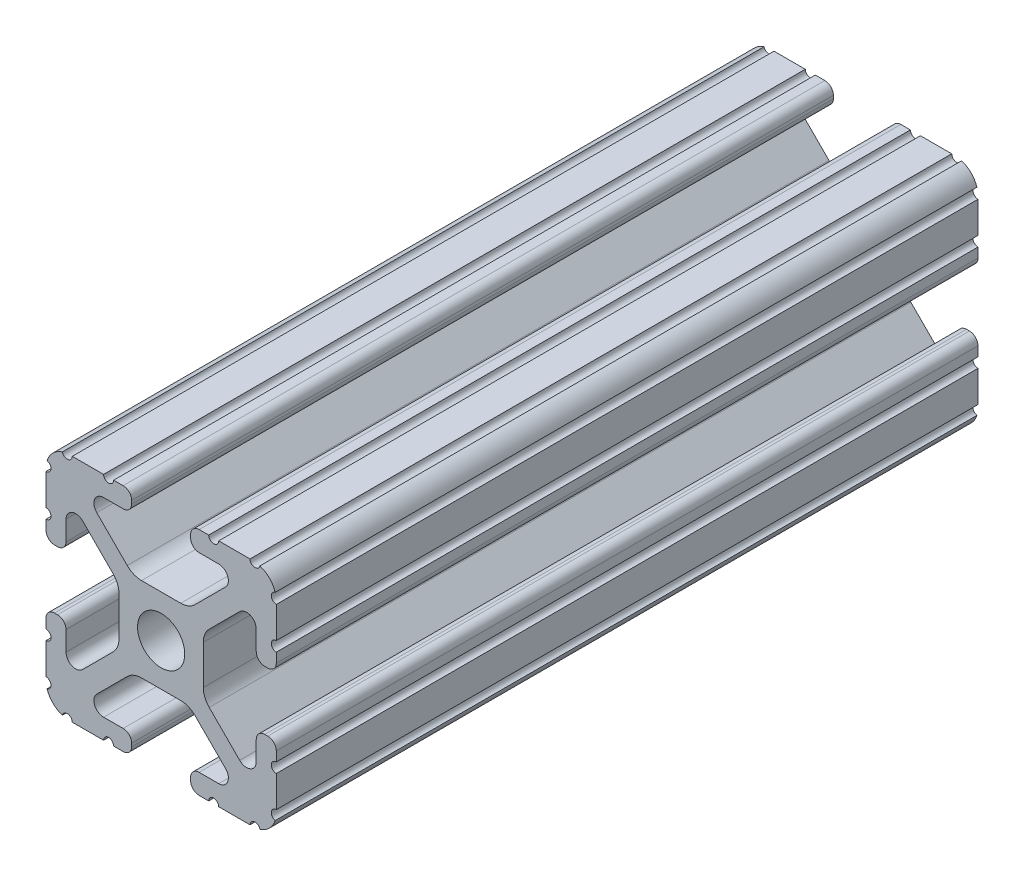
from build123d import *

# Parameters (mm, degrees)
BOSS_EXTRUDE1_DEPTH     = 38.7
SKETCH5_R               = 0.55245
CUT_EXTRUDE1_DEPTH      = 39.7
CUT_EXTRUDE1_DEPTH_BACK = 39.7


with BuildPart() as part:
    # Sketch4 → Boss-Extrude1 (new body, symmetric)
    with BuildSketch(Plane.XY):
        with BuildLine():
            Line((4.190365, -12.7), (10.11729625, -12.7))
            ThreePointArc((10.11729625, -12.7), (11.943543585, -11.943543585), (12.7, -10.11729625))
            Line((12.7, -10.11729625), (12.7, -4.190365))
            ThreePointArc((12.7, -4.190365), (12.42492494, -3.52627506), (11.760835, -3.2512))
            Line((11.760835, -3.2512), (11.429365, -3.2512))
            ThreePointArc((11.429365, -3.2512), (10.76527506, -3.52627506), (10.4902, -4.190365))
            Line((10.4902, -4.190365), (10.4902, -6.348478019))
            ThreePointArc((10.4902, -6.348478019), (9.830707141, -7.335478831), (8.666460301, -7.103895736))
            Line((8.666460301, -7.103895736), (5.299899128, -3.737334563))
            ThreePointArc((5.299899128, -3.737334563), (4.817571085, -3.015479634), (4.6482, -2.16399369))
            Line((4.6482, -2.16399369), (4.6482, 0))
            Line((4.6482, 0), (2.6035, 0))
            ThreePointArc((2.6035, 0), (1.840952505, -1.840952505), (0, -2.6035))
            Line((0, -2.6035), (0, -4.6482))
            Line((0, -4.6482), (2.16399369, -4.6482))
            ThreePointArc((2.16399369, -4.6482), (3.015479634, -4.817571085), (3.737334563, -5.299899128))
            Line((3.737334563, -5.299899128), (7.103895736, -8.666460301))
            ThreePointArc((7.103895736, -8.666460301), (7.335478831, -9.830707141), (6.348478019, -10.4902))
            Line((6.348478019, -10.4902), (4.190365, -10.4902))
            ThreePointArc((4.190365, -10.4902), (3.52627506, -10.76527506), (3.2512, -11.429365))
            Line((3.2512, -11.429365), (3.2512, -11.760835))
            ThreePointArc((3.2512, -11.760835), (3.52627506, -12.42492494), (4.190365, -12.7))
        make_face()
    extrude(amount=BOSS_EXTRUDE1_DEPTH, both=True)

    # Sketch5 → Cut-Extrude1 (cut, two sides)
    with BuildSketch(Plane.XY) as cut_extrude1_sk:
        with Locations((10.356153152, -12.7)):
            Circle(SKETCH5_R)
        with Locations((5.796028019, -12.7)):
            Circle(SKETCH5_R)
        with Locations((12.7, -10.356153152)):
            Circle(SKETCH5_R)
        with Locations((12.7, -5.796028019)):
            Circle(SKETCH5_R)
    extrude(amount=CUT_EXTRUDE1_DEPTH, mode=Mode.SUBTRACT)
    extrude(cut_extrude1_sk.sketch, amount=-CUT_EXTRUDE1_DEPTH_BACK, mode=Mode.SUBTRACT)

    # Mirror1: part across plane


with BuildPart() as part_1:
    add(part.part)
    add(part.part.mirror(Plane(origin=(0, 0, 0), x_dir=(0, 0, 1), z_dir=(1, 0, 0))))

    # Mirror2: part across plane


with BuildPart() as part_2:
    add(part_1.part)
    add(part_1.part.mirror(Plane.ZX))


solid = part_2.part
